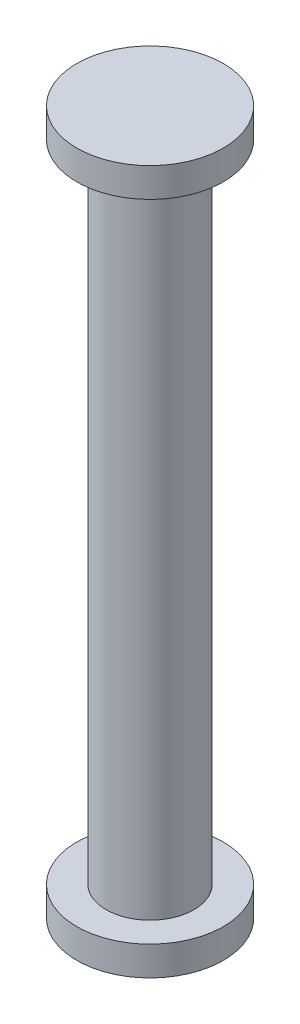
from build123d import *


with BuildPart() as part:
    # Sketch1 → Revolve1 (revolve)
    with BuildSketch(Plane.XY):
        Polygon((0, 0), (0, 24), (-2.5, 24), (-2.5, 23), (-1.5, 23), (-1.5, 1), (-2.5, 1), (-2.5, 0), align=None)
    revolve(axis=Axis((0, 0, 0), (0, 1, 0)))


solid = part.part
